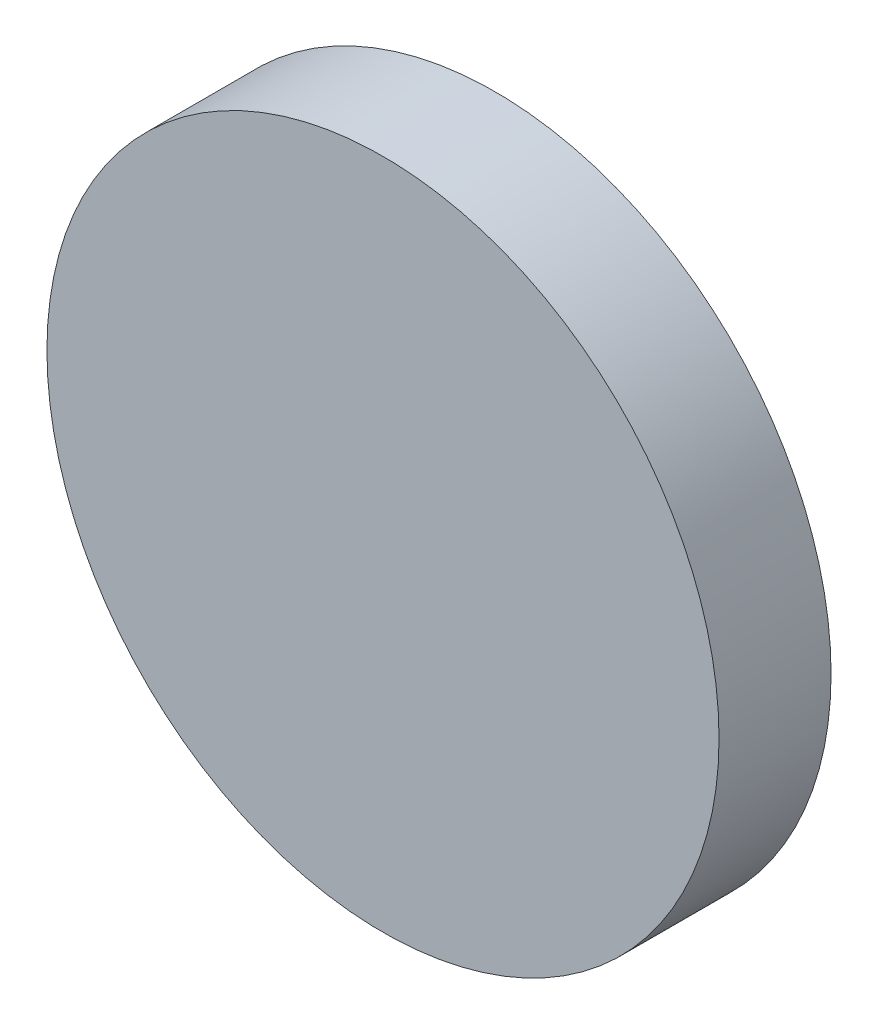
from build123d import *

# Parameters (mm, degrees)
SCHIZZO1_R                   = 6
ESTRUSIONE_ESTRUSIONE1_DEPTH = 2


with BuildPart() as part:
    # Schizzo1 → Estrusione-Estrusione1 (new body)
    with BuildSketch(Plane.XY):
        Circle(SCHIZZO1_R)
    extrude(amount=ESTRUSIONE_ESTRUSIONE1_DEPTH)


solid = part.part
